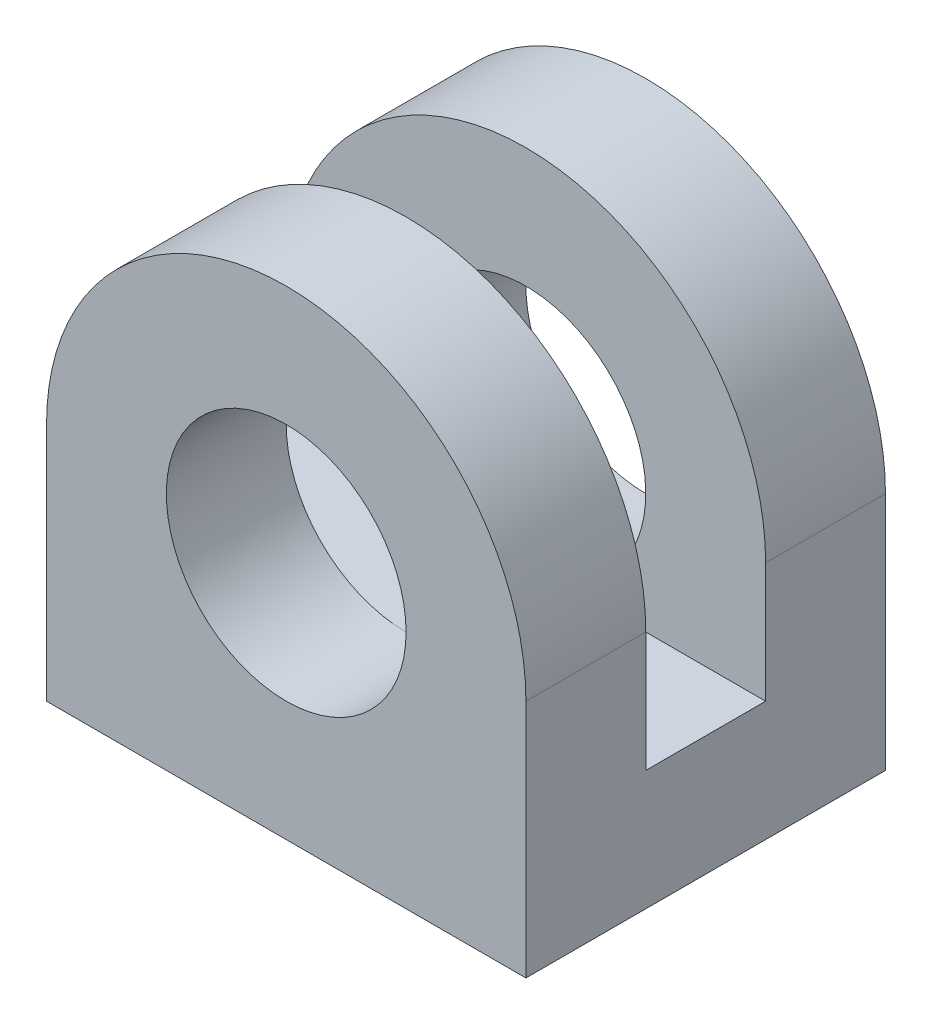
from build123d import *

# Parameters (mm, degrees)
ESBO_O1_R                = 10
RESSALTO_EXTRUS_O1_DEPTH = 15
ESBO_O2_W                = 10
ESBO_O2_H                = 36.681278326
CORTE_EXTRUS_O1_DEPTH    = 41


with BuildPart() as part:
    # Esboço1 → Ressalto-extrusão1 (new body, symmetric)
    with BuildSketch(Plane.XY):
        with BuildLine():
            Line((-20, 0), (20, 0))
            Line((20, 0), (20, 20))
            ThreePointArc((20, 20), (0, 40), (-20, 20))
            Line((-20, 20), (-20, 0))
        make_face()
        with Locations((0, 20)):
            Circle(ESBO_O1_R, mode=Mode.SUBTRACT)
    extrude(amount=RESSALTO_EXTRUS_O1_DEPTH, both=True)

    # Esboço2 → Corte-extrusão1 (cut, through all)
    with BuildSketch(Plane(origin=(20, 0, 0), x_dir=(0, 0, -1), z_dir=(1, 0, 0))):
        with Locations((0, 28.340639163)):
            Rectangle(ESBO_O2_W, ESBO_O2_H)
    extrude(amount=-CORTE_EXTRUS_O1_DEPTH, mode=Mode.SUBTRACT)


solid = part.part
